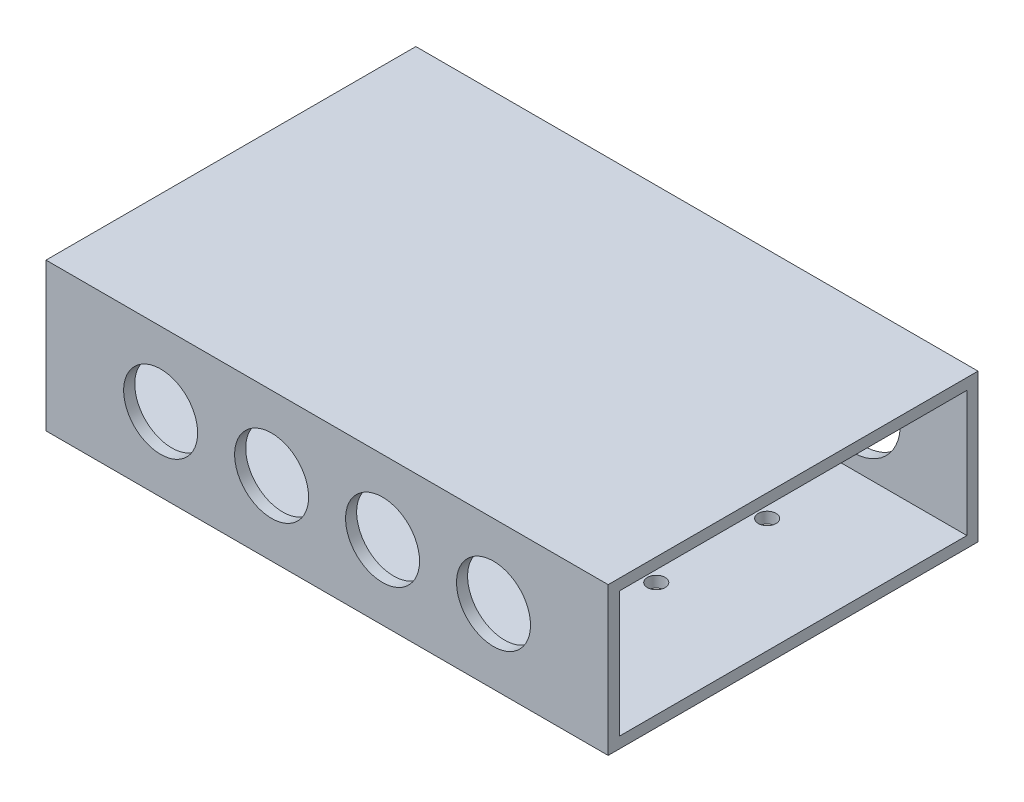
from build123d import *

# Parameters (mm, degrees)
SKETCH1_W           = 76
SKETCH1_H           = 50
BOSS_EXTRUDE1_DEPTH = 20
SKETCH2_W           = 47
SKETCH2_H           = 17
CUT_EXTRUDE1_DEPTH  = 76
SKETCH3_R           = 6.5
CUT_EXTRUDE2_DEPTH  = 2
SKETCH4_R           = 5
CUT_EXTRUDE3_DEPTH  = 2
SKETCH5_R           = 1.2
CUT_EXTRUDE4_DEPTH  = 2


with BuildPart() as part:
    # Sketch1 → Boss-Extrude1 (new body)
    with BuildSketch(Plane(origin=(0, 0, 0), x_dir=(1, 0, 0), z_dir=(0, 1, 0))):
        with Locations((11.529653553, 8.750876438)):
            Rectangle(SKETCH1_W, SKETCH1_H)
    extrude(amount=BOSS_EXTRUDE1_DEPTH)

    # Sketch2 → Cut-Extrude1 (cut)
    with BuildSketch(Plane.ZY.offset(26.470346447)):
        with Locations((-8.750876438, 10)):
            Rectangle(SKETCH2_W, SKETCH2_H)
    extrude(amount=-CUT_EXTRUDE1_DEPTH, mode=Mode.SUBTRACT)

    # Sketch3 → Cut-Extrude2 (cut)
    with BuildSketch(Plane(origin=(0, 0, -33.750876438), x_dir=(-1, 0, 0), z_dir=(0, 0, -1))):
        with Locations((10.970346447, 10)):
            Circle(SKETCH3_R)
        with Locations((-4.029653553, 10)):
            Circle(SKETCH3_R)
        with Locations((-19.029653553, 10)):
            Circle(SKETCH3_R)
        with Locations((-34.029653553, 10)):
            Circle(SKETCH3_R)
    extrude(amount=-CUT_EXTRUDE2_DEPTH, mode=Mode.SUBTRACT)

    # Sketch4 → Cut-Extrude3 (cut)
    with BuildSketch(Plane.XY.offset(16.249123562)):
        with Locations((-10.970346447, 10)):
            Circle(SKETCH4_R)
        with Locations((4.029653553, 10)):
            Circle(SKETCH4_R)
        with Locations((19.029653553, 10)):
            Circle(SKETCH4_R)
        with Locations((34.029653553, 10)):
            Circle(SKETCH4_R)
    extrude(amount=-CUT_EXTRUDE3_DEPTH, mode=Mode.SUBTRACT)

    # Sketch5 → Cut-Extrude4 (cut)
    with BuildSketch(Plane(origin=(0, 0, 0), x_dir=(-1, 0, 0), z_dir=(0, -1, 0))):
        with Locations(Location((-34.029653553, 20.750876438, 0), (0, 0, 90))):  # turned: the seam where the file's is
            Circle(SKETCH5_R)
        with Locations(Location((-19.029653553, 20.750876438, 0), (0, 0, 90))):  # turned: the seam where the file's is
            Circle(SKETCH5_R)
        with Locations(Location((-4.029653553, 20.750876438, 0), (0, 0, 90))):  # turned: the seam where the file's is
            Circle(SKETCH5_R)
        with Locations(Location((10.970346447, 20.750876438, 0), (0, 0, 90))):  # turned: the seam where the file's is
            Circle(SKETCH5_R)
        with Locations(Location((-19.029653553, 5.750876438, 0), (0, 0, 90))):  # turned: the seam where the file's is
            Circle(SKETCH5_R)
        with Locations(Location((-4.029653553, 5.750876438, 0), (0, 0, 90))):  # turned: the seam where the file's is
            Circle(SKETCH5_R)
        with Locations(Location((10.970346447, 5.750876438, 0), (0, 0, 90))):  # turned: the seam where the file's is
            Circle(SKETCH5_R)
        with Locations(Location((-34.029653553, 5.750876438, 0), (0, 0, 90))):  # turned: the seam where the file's is
            Circle(SKETCH5_R)
    extrude(amount=-CUT_EXTRUDE4_DEPTH, mode=Mode.SUBTRACT)


solid = part.part
